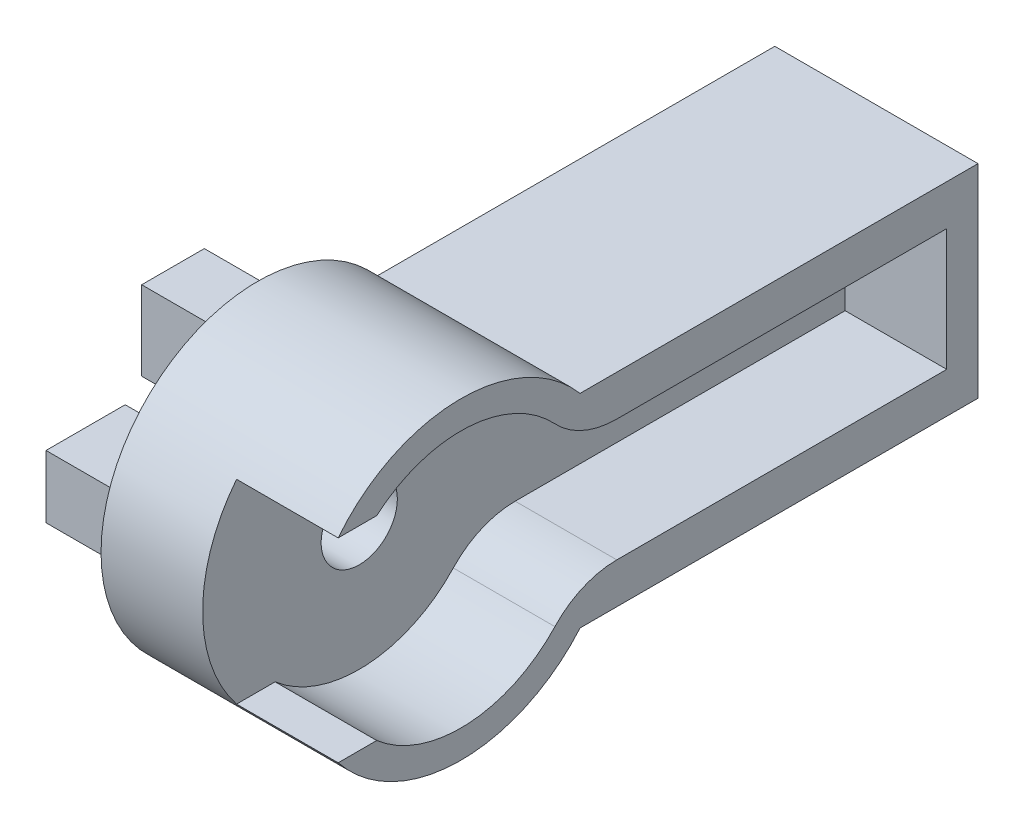
from build123d import *

# Parameters (mm, degrees)
BOSS_EXTRUDE1_DEPTH = 12
SKETCH2_R           = 7.6
SKETCH2_W           = 22
SKETCH2_H           = 7.2
SKETCH2_W_2         = 6.090233647
SKETCH2_H_2         = 11.5
CUT_EXTRUDE1_DEPTH  = 6
FILLET1_R           = 5
SKETCH3_R           = 2.25
SKETCH3_R_2         = 1.65
CUT_EXTRUDE2_DEPTH  = 6
BOSS_EXTRUDE2_DEPTH = 5
SKETCH6_R           = 3.375
CUT_EXTRUDE3_DEPTH  = 5


with BuildPart() as part:
    # Sketch1 → Boss-Extrude1 (new body)
    with BuildSketch(Plane(origin=(0, 0, 0), x_dir=(0, 0, -1), z_dir=(1, 0, 0))):
        with BuildLine():
            Line((30.54006392, 6), (7.04006392, 6))
            ThreePointArc((7.04006392, 6), (8.679950785, 3.197022735), (9.25, 0))
            ThreePointArc((9.25, 0), (8.679950785, -3.197022735), (7.04006392, -6))
            Line((7.04006392, -6), (30.54006392, -6))
            Line((30.54006392, -6), (30.54006392, 6))
        make_face()
        with BuildLine():
            ThreePointArc((9.25, 0), (8.679950785, 3.197022735), (7.04006392, 6))
            Line((7.04006392, 6), (7.04006392, -6))
            ThreePointArc((7.04006392, -6), (8.679950785, -3.197022735), (9.25, 0))
        make_face()
        with BuildLine():
            Line((7.04006392, -6), (7.04006392, 6))
            ThreePointArc((7.04006392, 6), (-9.25, 0), (7.04006392, -6))
        make_face()
    extrude(amount=BOSS_EXTRUDE1_DEPTH)

    # Sketch2 → Cut-Extrude1 (cut)
    with BuildSketch(Plane(origin=(12, 0, 0), x_dir=(0, 0, -1), z_dir=(1, 0, 0))):
        Circle(SKETCH2_R)
        with Locations((17.693280212, 0)):
            Rectangle(SKETCH2_W, SKETCH2_H)
        with Locations((-8.014774759, 0)):
            Rectangle(SKETCH2_W_2, SKETCH2_H_2)
    extrude(amount=-CUT_EXTRUDE1_DEPTH, mode=Mode.SUBTRACT)

    # Fillet1
    fillet1_edges = [part.edges().sort_by_distance(p)[0] for p in [
        (9, 3.6, -6.693280212),
        (9, -3.6, -6.693280212),
    ]]
    fillet(fillet1_edges, radius=FILLET1_R)

    # Sketch3 → Cut-Extrude2 (cut)
    with BuildSketch(Plane(origin=(6, 0, 0), x_dir=(0, 0, -1), z_dir=(1, 0, 0))):
        Circle(SKETCH3_R)
        with Locations((20.5, 0)):
            Circle(SKETCH3_R_2)
        with Locations((24.5, 0)):
            Circle(SKETCH3_R_2)
    extrude(amount=-CUT_EXTRUDE2_DEPTH, mode=Mode.SUBTRACT)

    # Sketch5 → Boss-Extrude2 (add)
    with BuildSketch(Plane.ZY):
        with BuildLine():
            Line((-1.85, 1.85), (-7.5, 1.85))
            Line((-7.5, 1.85), (-7.5, -1.85))
            Line((-7.5, -1.85), (-1.85, -1.85))
            Line((-1.85, -1.85), (-1.85, -1.280624847))
            ThreePointArc((-1.85, -1.280624847), (-2.25, 0), (-1.85, 1.280624847))
            Line((-1.85, 1.280624847), (-1.85, 1.85))
        make_face()
        with BuildLine():
            Line((-1.85, 7.5), (-1.85, 1.85))
            Line((-1.85, 1.85), (-1.280624847, 1.85))
            ThreePointArc((-1.280624847, 1.85), (0, 2.25), (1.280624847, 1.85))
            Line((1.280624847, 1.85), (1.85, 1.85))
            Line((1.85, 1.85), (1.85, 7.5))
            Line((1.85, 7.5), (-1.85, 7.5))
        make_face()
        with BuildLine():
            Line((7.5, 1.85), (1.85, 1.85))
            Line((1.85, 1.85), (1.85, 1.280624847))
            ThreePointArc((1.85, 1.280624847), (2.147673159, 0.670820393), (2.25, 0))
            ThreePointArc((2.25, 0), (2.147673159, -0.670820393), (1.85, -1.280624847))
            Line((1.85, -1.280624847), (1.85, -1.85))
            Line((1.85, -1.85), (7.5, -1.85))
            Line((7.5, -1.85), (7.5, 1.85))
        make_face()
        with BuildLine():
            Line((-1.280624847, -1.85), (-1.85, -1.85))
            Line((-1.85, -1.85), (-1.85, -7.5))
            Line((-1.85, -7.5), (1.85, -7.5))
            Line((1.85, -7.5), (1.85, -1.85))
            Line((1.85, -1.85), (1.280624847, -1.85))
            ThreePointArc((1.280624847, -1.85), (0, -2.25), (-1.280624847, -1.85))
        make_face()
        with BuildLine():
            Line((-1.280624847, 1.85), (-1.85, 1.85))
            Line((-1.85, 1.85), (-1.85, 1.280624847))
            ThreePointArc((-1.85, 1.280624847), (-1.590990258, 1.590990258), (-1.280624847, 1.85))
        make_face()
        with BuildLine():
            Line((1.85, 1.85), (1.280624847, 1.85))
            ThreePointArc((1.280624847, 1.85), (1.590990258, 1.590990258), (1.85, 1.280624847))
            Line((1.85, 1.280624847), (1.85, 1.85))
        make_face()
        with BuildLine():
            ThreePointArc((1.85, -1.280624847), (1.590990258, -1.590990258), (1.280624847, -1.85))
            Line((1.280624847, -1.85), (1.85, -1.85))
            Line((1.85, -1.85), (1.85, -1.280624847))
        make_face()
        with BuildLine():
            Line((-1.85, -1.280624847), (-1.85, -1.85))
            Line((-1.85, -1.85), (-1.280624847, -1.85))
            ThreePointArc((-1.280624847, -1.85), (-1.590990258, -1.590990258), (-1.85, -1.280624847))
        make_face()
    extrude(amount=BOSS_EXTRUDE2_DEPTH)

    # Sketch6 → Cut-Extrude3 (cut)
    with BuildSketch(Plane.ZY.offset(5)):
        Circle(SKETCH6_R)
    extrude(amount=-CUT_EXTRUDE3_DEPTH, mode=Mode.SUBTRACT)


solid = part.part
